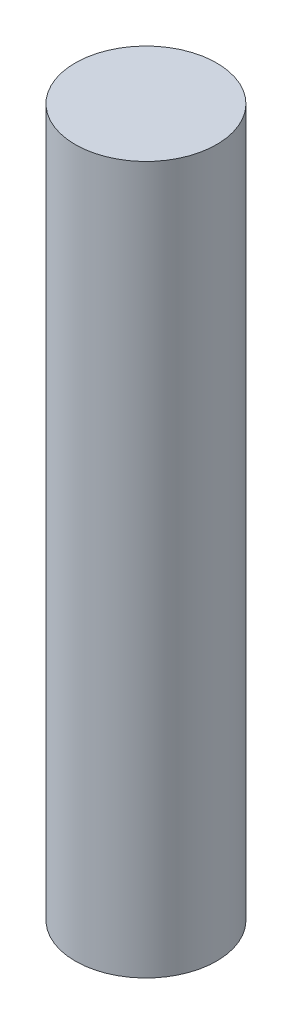
from build123d import *

# Parameters (mm, degrees)
SKETCH1_R           = 2.286
BOSS_EXTRUDE1_DEPTH = 22.86


with BuildPart() as part:
    # Sketch1 → Boss-Extrude1 (new body)
    with BuildSketch(Plane(origin=(0, 0, 0), x_dir=(1, 0, 0), z_dir=(0, 1, 0))):
        Circle(SKETCH1_R)
    extrude(amount=BOSS_EXTRUDE1_DEPTH)


solid = part.part
